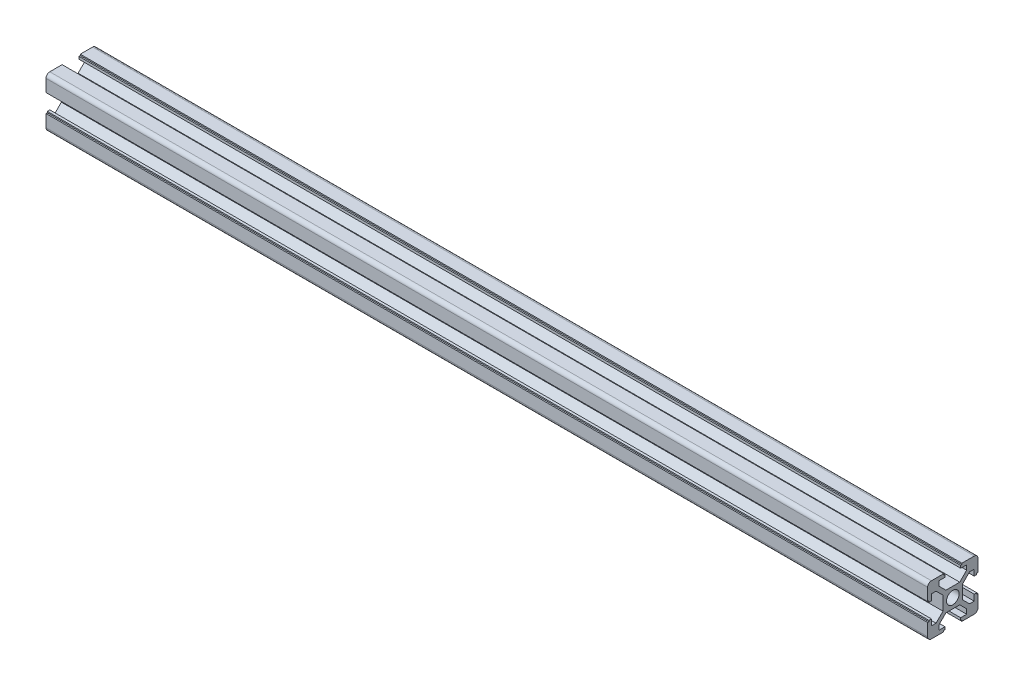
from build123d import *

# Parameters (mm, degrees)
SKETCH1_R                = 2.5
F_20_X_20_X_R1_5_1_DEPTH = 350


with BuildPart() as part:
    # Sketch1 → 铝型材 20 X 20 X R1.5(1) (new body)
    with BuildSketch(Plane(origin=(0, 0, 0), x_dir=(0, 0, -1), z_dir=(1, 0, 0))):
        with BuildLine():
            Line((-3.6, 10), (-3.6, 9.5))
            Line((-3.6, 9.5), (-3.1, 9.5))
            Line((-3.1, 9.5), (-3.1, 8.5))
            Line((-3.1, 8.5), (-5.5, 8.5))
            Line((-5.5, 8.5), (-5.5, 6.65))
            Line((-5.5, 6.65), (-2.75, 3.9))
            Line((-2.75, 3.9), (2.75, 3.9))
            Line((2.75, 3.9), (5.5, 6.65))
            Line((5.5, 6.65), (5.5, 8.5))
            Line((5.5, 8.5), (3.1, 8.5))
            Line((3.1, 8.5), (3.1, 9.5))
            Line((3.1, 9.5), (3.6, 9.5))
            Line((3.6, 9.5), (3.6, 10))
            Line((3.6, 10), (8.5, 10))
            ThreePointArc((8.5, 10), (9.560660172, 9.560660172), (10, 8.5))
            Line((10, 8.5), (10, 3.6))
            Line((10, 3.6), (9.5, 3.6))
            Line((9.5, 3.6), (9.5, 3.1))
            Line((9.5, 3.1), (8.5, 3.1))
            Line((8.5, 3.1), (8.5, 5.5))
            Line((8.5, 5.5), (6.65, 5.5))
            Line((6.65, 5.5), (3.9, 2.75))
            Line((3.9, 2.75), (3.9, -2.75))
            Line((3.9, -2.75), (6.65, -5.5))
            Line((6.65, -5.5), (8.5, -5.5))
            Line((8.5, -5.5), (8.5, -3.1))
            Line((8.5, -3.1), (9.5, -3.1))
            Line((9.5, -3.1), (9.5, -3.6))
            Line((9.5, -3.6), (10, -3.6))
            Line((10, -3.6), (10, -8.5))
            ThreePointArc((10, -8.5), (9.560660172, -9.560660172), (8.5, -10))
            Line((8.5, -10), (3.6, -10))
            Line((3.6, -10), (3.6, -9.5))
            Line((3.6, -9.5), (3.1, -9.5))
            Line((3.1, -9.5), (3.1, -8.5))
            Line((3.1, -8.5), (5.5, -8.5))
            Line((5.5, -8.5), (5.5, -6.65))
            Line((5.5, -6.65), (2.75, -3.9))
            Line((2.75, -3.9), (-2.75, -3.9))
            Line((-2.75, -3.9), (-5.5, -6.65))
            Line((-5.5, -6.65), (-5.5, -8.5))
            Line((-5.5, -8.5), (-3.1, -8.5))
            Line((-3.1, -8.5), (-3.1, -9.5))
            Line((-3.1, -9.5), (-3.6, -9.5))
            Line((-3.6, -9.5), (-3.6, -10))
            Line((-3.6, -10), (-8.5, -10))
            ThreePointArc((-8.5, -10), (-9.560660172, -9.560660172), (-10, -8.5))
            Line((-10, -8.5), (-10, -3.6))
            Line((-10, -3.6), (-9.5, -3.6))
            Line((-9.5, -3.6), (-9.5, -3.1))
            Line((-9.5, -3.1), (-8.5, -3.1))
            Line((-8.5, -3.1), (-8.5, -5.5))
            Line((-8.5, -5.5), (-6.65, -5.5))
            Line((-6.65, -5.5), (-3.9, -2.75))
            Line((-3.9, -2.75), (-3.9, 2.75))
            Line((-3.9, 2.75), (-6.65, 5.5))
            Line((-6.65, 5.5), (-8.5, 5.5))
            Line((-8.5, 5.5), (-8.5, 3.1))
            Line((-8.5, 3.1), (-9.5, 3.1))
            Line((-9.5, 3.1), (-9.5, 3.6))
            Line((-9.5, 3.6), (-10, 3.6))
            Line((-10, 3.6), (-10, 8.5))
            ThreePointArc((-10, 8.5), (-9.560660172, 9.560660172), (-8.5, 10))
            Line((-8.5, 10), (-3.6, 10))
        make_face()
        Circle(SKETCH1_R, mode=Mode.SUBTRACT)
    extrude(amount=F_20_X_20_X_R1_5_1_DEPTH)


solid = part.part
